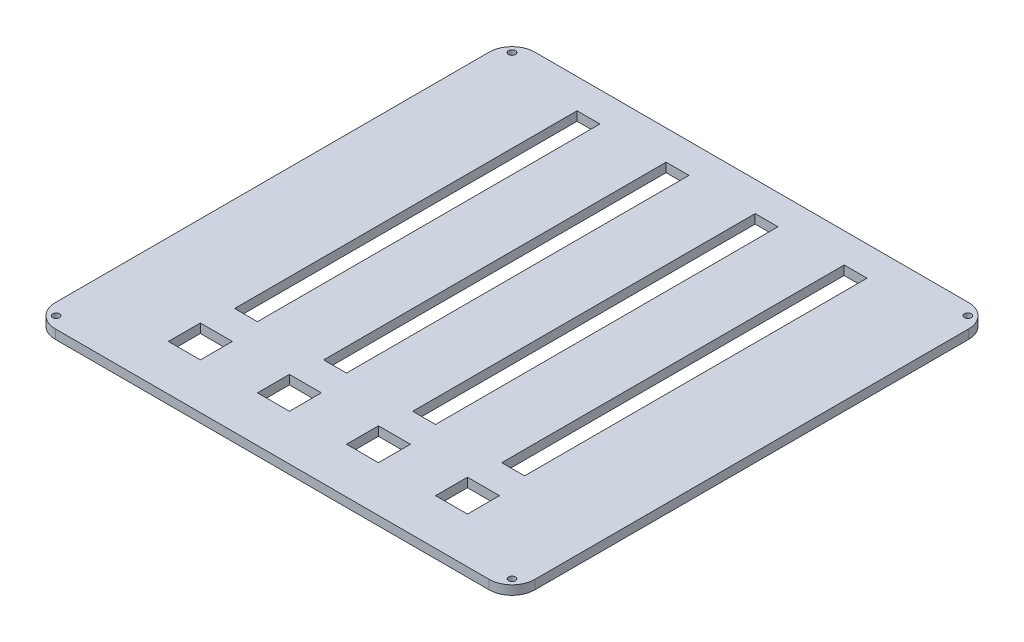
from build123d import *

# Parameters (mm, degrees)
SKETCH1_W          = 210
SKETCH1_H          = 210
MAINEXTRUDE_DEPTH  = 4
SKETCH1_6_R        = 1.5
SCREWHOLES_DEPTH   = 4
ROUNDEDCORNERS_R   = 10
SKETCH3_W          = 14
SKETCH3_H          = 14
SKETCH3_W_2        = 10
SKETCH3_H_2        = 150
CUTOUTS_DEPTH      = 10
SKETCH6_R          = 0.98
CUT_EXTRUDE1_DEPTH = 1


with BuildPart() as part:
    # Sketch1 → MainExtrude (new body)
    with BuildSketch(Plane(origin=(0, 0, 0), x_dir=(1, 0, 0), z_dir=(0, 1, 0))):
        Rectangle(SKETCH1_W, SKETCH1_H)
    extrude(amount=MAINEXTRUDE_DEPTH)

    # Sketch1_6 → ScrewHoles (cut)
    with BuildSketch(Plane(origin=(0, 0, 0), x_dir=(1, 0, 0), z_dir=(0, 1, 0))):
        with Locations((-99.833273811, 99.833273811)):
            Circle(SKETCH1_6_R)
        with Locations((-99.833273811, -99.833273811)):
            Circle(SKETCH1_6_R)
        with Locations((99.833273811, -99.833273811)):
            Circle(SKETCH1_6_R)
        with Locations((99.833273811, 99.833273811)):
            Circle(SKETCH1_6_R)
    extrude(amount=SCREWHOLES_DEPTH, mode=Mode.SUBTRACT)

    # RoundedCorners
    roundedcorners_edges = [part.edges().sort_by_distance(p)[0] for p in [
        (-105, 2, -105),
        (-105, 2, 105),
        (105, 2, 105),
        (105, 2, -105),
    ]]
    fillet(roundedcorners_edges, radius=ROUNDEDCORNERS_R)

    # Sketch3 → Cutouts (cut)
    with BuildSketch(Plane(origin=(0, 4, 0), x_dir=(1, 0, 0), z_dir=(0, 1, 0))):
        with Locations((-58.5, -78)):
            Rectangle(SKETCH3_W, SKETCH3_H)
        with Locations((-19.5, -78)):
            Rectangle(SKETCH3_W, SKETCH3_H)
        with Locations((19.5, -78)):
            Rectangle(SKETCH3_W, SKETCH3_H)
        with Locations((58.5, -78)):
            Rectangle(SKETCH3_W, SKETCH3_H)
        with Locations((-19.5, 17)):
            Rectangle(SKETCH3_W_2, SKETCH3_H_2)
        with Locations((-58.5, 17)):
            Rectangle(SKETCH3_W_2, SKETCH3_H_2)
        with Locations((19.5, 17)):
            Rectangle(SKETCH3_W_2, SKETCH3_H_2)
        with Locations((58.5, 17)):
            Rectangle(SKETCH3_W_2, SKETCH3_H_2)
    extrude(amount=-CUTOUTS_DEPTH, mode=Mode.SUBTRACT)

    # Sketch6 → Cut-Extrude1 (cut)
    with BuildSketch(Plane.XZ):
        with Locations((-70, 62)):
            Circle(SKETCH6_R)
        with Locations((70, 62)):
            Circle(SKETCH6_R)
        with Locations((70, -98)):
            Circle(SKETCH6_R)
        with Locations((-70, -98)):
            Circle(SKETCH6_R)
    extrude(amount=-CUT_EXTRUDE1_DEPTH, mode=Mode.SUBTRACT)


solid = part.part
